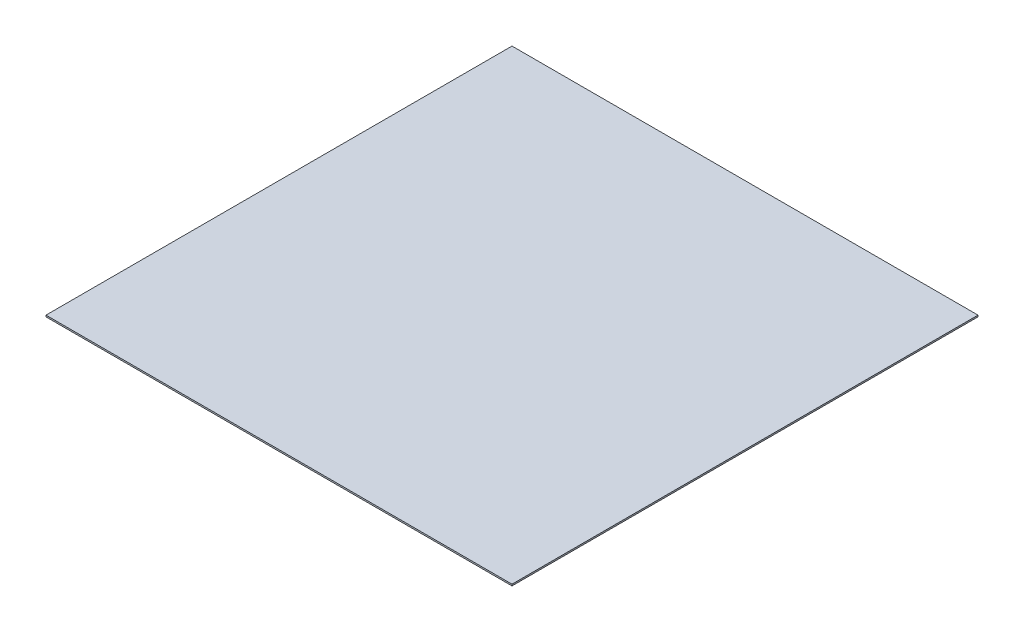
from build123d import *

# Parameters (mm, degrees)
SKETCH1_W           = 3000
SKETCH1_H           = 3000
BOSS_EXTRUDE1_DEPTH = 10


with BuildPart() as part:
    # Sketch1 → Boss-Extrude1 (new body)
    with BuildSketch(Plane(origin=(0, 0, 0), x_dir=(1, 0, 0), z_dir=(0, 1, 0))):
        Rectangle(SKETCH1_W, SKETCH1_H)
    extrude(amount=BOSS_EXTRUDE1_DEPTH)


solid = part.part
